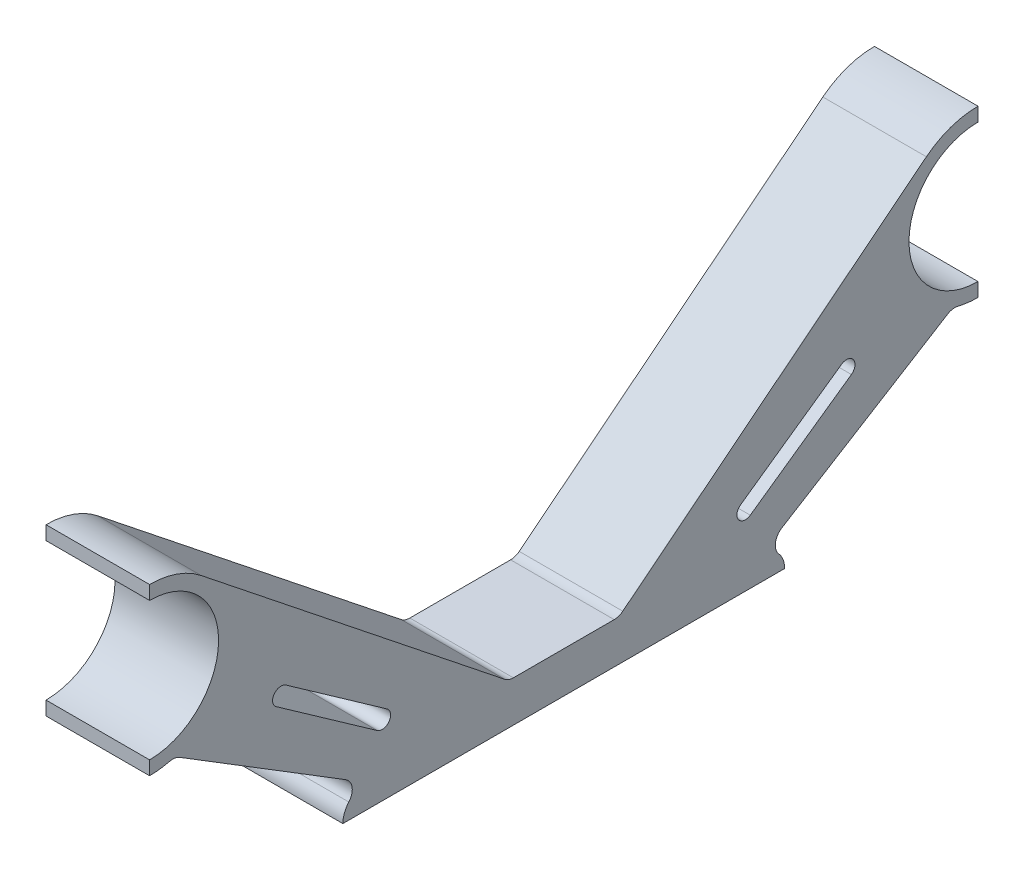
from build123d import *

# Parameters (mm, degrees)
ESTRUSIONE_ESTRUSIONE1_DEPTH = 3.75
RACCORDO2_R                  = 1


with BuildPart() as part:
    # Schizzo1 → Estrusione-Estrusione1 (new body, symmetric)
    with BuildSketch(Plane(origin=(0, 0, 0), x_dir=(0, 0, -1), z_dir=(1, 0, 0))):
        with BuildLine():
            Line((-30, 22), (-30, 21))
            ThreePointArc((-30, 21), (-25, 16), (-30, 11))
            Line((-30, 11), (-30, 10))
            ThreePointArc((-30, 10), (-29.075946517, 10.07158325), (-28.173941951, 10.284624946))
            Line((-28.173941951, 10.284624946), (-14.279791844, 1.720208156))
            ThreePointArc((-14.279791844, 1.720208156), (-15.496162696, 1.216370852), (-16, 0))
            Line((-16, 0), (16, 0))
            ThreePointArc((16, 0), (15.496162696, 1.216370852), (14.279791844, 1.720208156))
            Line((14.279791844, 1.720208156), (28.173941951, 10.284624946))
            ThreePointArc((28.173941951, 10.284624946), (29.075946517, 10.07158325), (30, 10))
            Line((30, 10), (30, 11))
            ThreePointArc((30, 11), (25, 16), (30, 21))
            Line((30, 21), (30, 22))
            ThreePointArc((30, 22), (28.020680207, 21.664123335), (26.262962858, 20.694097719))
            Line((26.262962858, 20.694097719), (4, 2.970240215))
            Line((4, 2.970240215), (-4, 2.970240215))
            Line((-4, 2.970240215), (-26.262962858, 20.694097719))
            ThreePointArc((-26.262962858, 20.694097719), (-28.020680207, 21.664123335), (-30, 22))
        make_face()
        with BuildLine():
            Line((-20.125796974, 10.754754637), (-12.80100478, 5.593685162))
            ThreePointArc((-12.80100478, 5.593685162), (-12.653117343, 4.740293889), (-13.506508616, 4.592406452))
            Line((-13.506508616, 4.592406452), (-20.83130081, 9.753475926))
            ThreePointArc((-20.83130081, 9.753475926), (-20.979188247, 10.606867199), (-20.125796974, 10.754754637))
        make_face(mode=Mode.SUBTRACT)
        with BuildLine():
            Line((20.125796974, 10.754754637), (12.80100478, 5.593685162))
            ThreePointArc((12.80100478, 5.593685162), (12.653117343, 4.740293889), (13.506508616, 4.592406452))
            Line((13.506508616, 4.592406452), (20.83130081, 9.753475926))
            ThreePointArc((20.83130081, 9.753475926), (20.979188247, 10.606867199), (20.125796974, 10.754754637))
        make_face(mode=Mode.SUBTRACT)
    extrude(amount=ESTRUSIONE_ESTRUSIONE1_DEPTH, both=True)

    # Raccordo2
    raccordo2_edges = [part.edges().sort_by_distance(p)[0] for p in [
        (0, 2.970240215, 4),
        (0, 2.970240215, -4),
        (0, 10.284624946, -28.173941951),
        (0, 1.720208156, -14.279791844),
        (0, 1.720208156, 14.279791844),
        (0, 10.284624946, 28.173941951),
    ]]
    fillet(raccordo2_edges, radius=RACCORDO2_R)


solid = part.part
